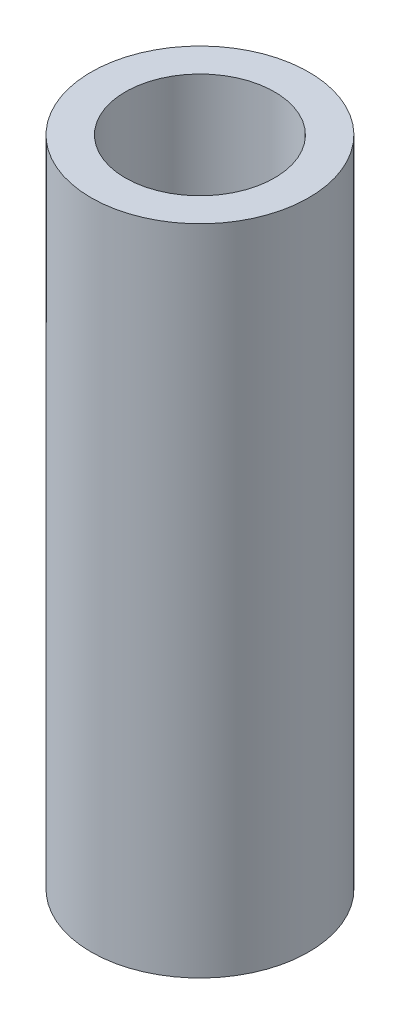
from build123d import *

# Parameters (mm, degrees)
SKETCH1_R           = 4.7625
SKETCH1_R_2         = 3.2639
BOSS_EXTRUDE1_DEPTH = 28.575


with BuildPart() as part:
    # Sketch1 → Boss-Extrude1 (new body)
    with BuildSketch(Plane(origin=(0, 0, 0), x_dir=(1, 0, 0), z_dir=(0, 1, 0))):
        Circle(SKETCH1_R)
        Circle(SKETCH1_R_2, mode=Mode.SUBTRACT)
    extrude(amount=BOSS_EXTRUDE1_DEPTH)


solid = part.part
